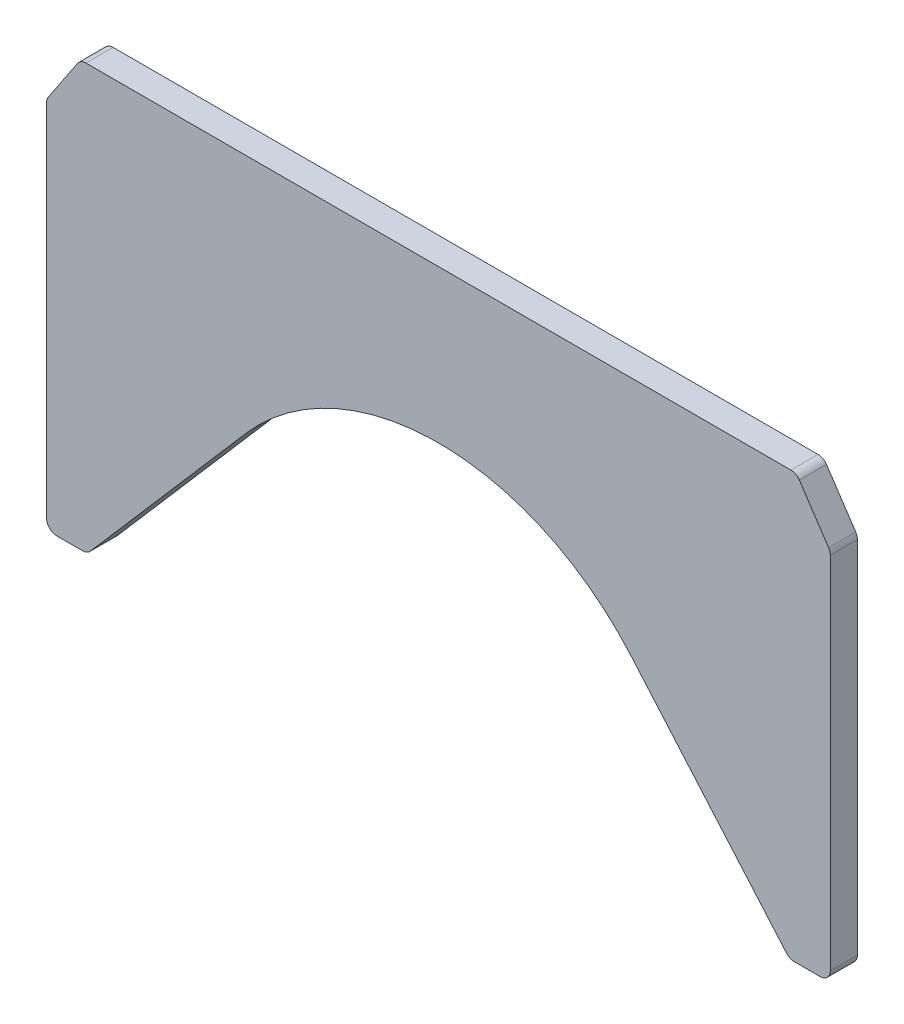
from build123d import *

# Parameters (mm, degrees)
EXTRUDE1_DEPTH = 8


with BuildPart() as part:
    # Sketch1 → Extrude1 (new body)
    with BuildSketch(Plane.XY):
        with BuildLine():
            Line((-103.894448725, 0), (103.894448725, 0))
            ThreePointArc((103.894448725, 0), (105.310022501, -0.354976204), (106.390599608, -1.335899411))
            Line((106.390599608, -1.335899411), (114.996150883, -14.244226325))
            ThreePointArc((114.996150883, -14.244226325), (115.371276079, -15.038974467), (115.5, -15.908326913))
            Line((115.5, -15.908326913), (115.5, -122))
            ThreePointArc((115.5, -122), (114.621320344, -124.121320344), (112.5, -125))
            Line((112.5, -125), (104.871428571, -125))
            ThreePointArc((104.871428571, -125), (103.624149291, -124.728423427), (102.602691232, -123.96286293))
            Line((102.602691232, -123.96286293), (56.718433491, -70.928426739))
            ThreePointArc((56.718433491, -70.928426739), (0, -45), (-56.718433491, -70.928426739))
            Line((-56.718433491, -70.928426739), (-102.602691232, -123.96286293))
            ThreePointArc((-102.602691232, -123.96286293), (-103.624149291, -124.728423427), (-104.871428571, -125))
            Line((-104.871428571, -125), (-112.5, -125))
            ThreePointArc((-112.5, -125), (-114.621320344, -124.121320344), (-115.5, -122))
            Line((-115.5, -122), (-115.5, -15.908326913))
            ThreePointArc((-115.5, -15.908326913), (-115.371276079, -15.038974467), (-114.996150883, -14.244226325))
            Line((-114.996150883, -14.244226325), (-106.390599608, -1.335899411))
            ThreePointArc((-106.390599608, -1.335899411), (-105.310022501, -0.354976204), (-103.894448725, 0))
        make_face()
    extrude(amount=EXTRUDE1_DEPTH)


solid = part.part
